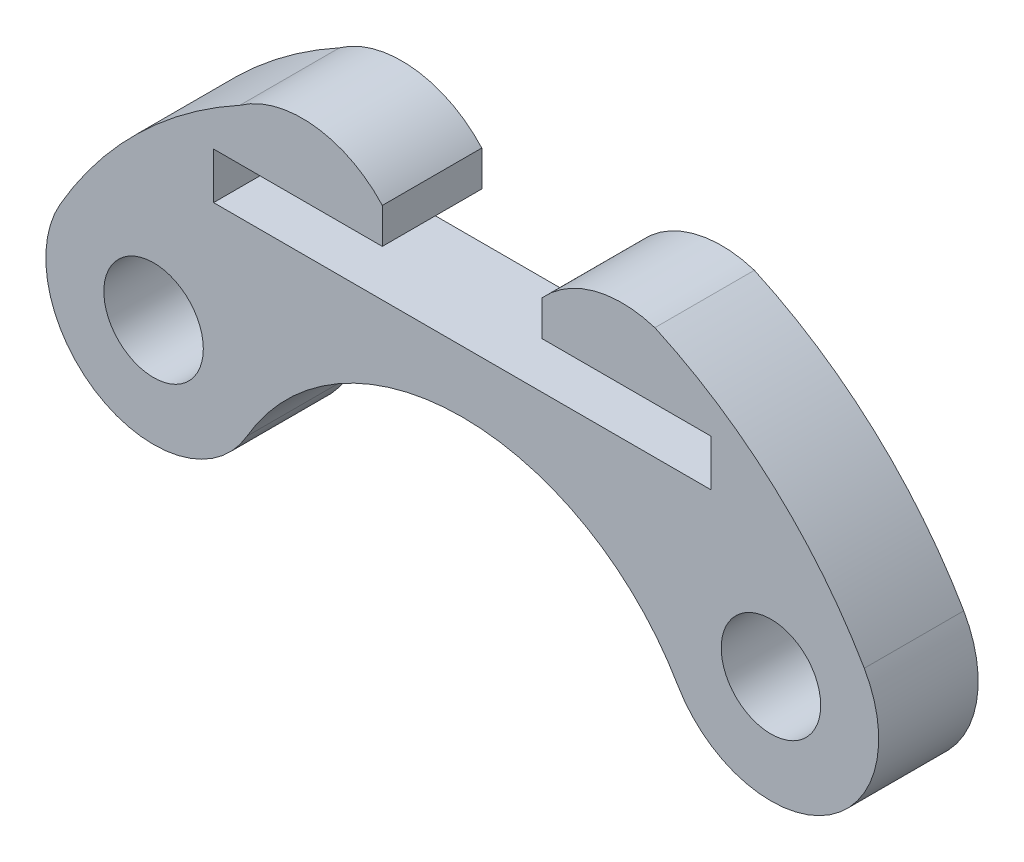
from build123d import *

# Parameters (mm, degrees)
ESQUISSE1_R        = 1.5
BOSS_EXTRU_2_DEPTH = 3


with BuildPart() as part:
    # Esquisse1 → Boss.-Extru.2 (new body)
    with BuildSketch(Plane.XY):
        with BuildLine():
            Line((-2.411034891, 11.820685714), (-2.411034891, 10.75))
            Line((-2.411034891, 10.75), (-7.5, 10.75))
            Line((-7.5, 10.75), (-7.5, 9.35))
            Line((-7.5, 9.35), (7.5, 9.35))
            Line((7.5, 9.35), (7.5, 10.75))
            Line((7.5, 10.75), (2.411034891, 10.75))
            Line((2.411034891, 10.75), (2.411034891, 11.820685714))
            ThreePointArc((2.411034891, 11.820685714), (3.975330286, 12.779130538), (5.80943088, 12.737759334))
            ThreePointArc((5.80943088, 12.737759334), (9.414650572, 10.36167721), (12.124355653, 7))
            ThreePointArc((12.124355653, 7), (10.934773091, 2.560417438), (6.495190528, 3.75))
            ThreePointArc((6.495190528, 3.75), (0, 7.5), (-6.495190528, 3.75))
            ThreePointArc((-6.495190528, 3.75), (-10.934773091, 2.560417438), (-12.124355653, 7))
            ThreePointArc((-12.124355653, 7), (-9.780131311, 10.017436376), (-6.707371512, 12.288660114))
            ThreePointArc((-6.707371512, 12.288660114), (-4.47014813, 12.872261577), (-2.411034891, 11.820685714))
        make_face()
        with Locations((9.309773091, 5.375)):
            Circle(ESQUISSE1_R, mode=Mode.SUBTRACT)
        with Locations((-9.309773091, 5.375)):
            Circle(ESQUISSE1_R, mode=Mode.SUBTRACT)
    extrude(amount=BOSS_EXTRU_2_DEPTH)


solid = part.part
